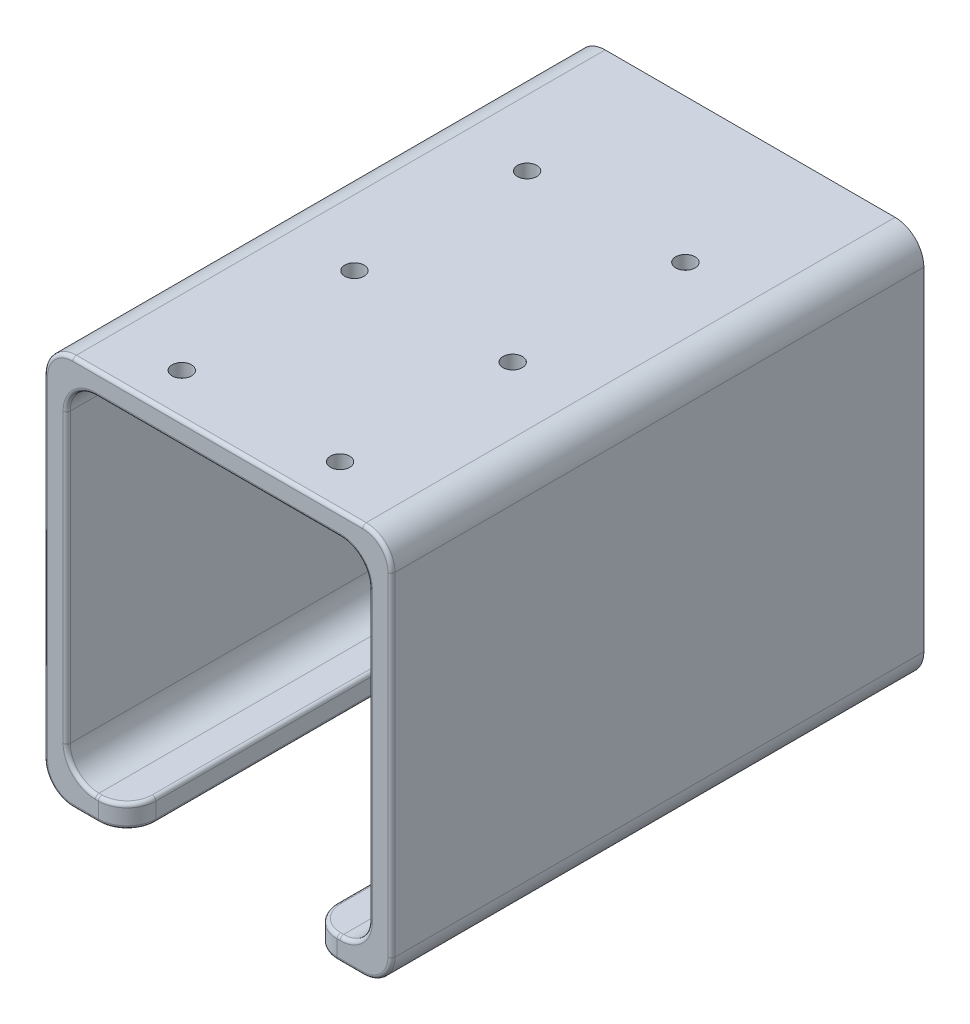
from build123d import *

# Parameters (mm, degrees)
SKETCH2_W               = 76.675
SKETCH2_H               = 86.2
SKETCH2_W_2             = 66.675
SKETCH2_H_2             = 76.2
BOSS_EXTRUDE1_DEPTH     = 152.4
CUT_EXTRUDE1_REACH      = 181.237
FILLET1_R               = 6.35
SKETCH5_R               = 2.13995
CUT_EXTRUDE2_DEPTH      = 177.886867535
LPATTERN1_COUNT         = 4
LPATTERN1_PITCH         = 38.1
MIRROR3_COPY_1_SKETCH_R = 2.13995
MIRROR3_COPY_1_DEPTH    = 177.886867535
MIRROR3_COPY_2_SKETCH_R = 2.13995
MIRROR3_COPY_2_DEPTH    = 177.886867535
MIRROR3_COPY_3_SKETCH_R = 2.13995
MIRROR3_COPY_3_DEPTH    = 177.886867535
CUT_EXTRUDE3_START      = -34.925
CUT_EXTRUDE3_DEPTH      = 34.925
FILLET2_R               = 0.79375


with BuildPart() as part:
    # Sketch2 → Boss-Extrude1 (new body)
    with BuildSketch(Plane.XY):
        Rectangle(SKETCH2_W, SKETCH2_H)
        Rectangle(SKETCH2_W_2, SKETCH2_H_2, mode=Mode.SUBTRACT)
    extrude(amount=BOSS_EXTRUDE1_DEPTH)

    # Sketch3 → Cut-Extrude1 (cut, up to next)
    with BuildSketch(Plane.XZ.offset(43.1), mode=Mode.PRIVATE) as cut_extrude1_sk1:
        with BuildLine():
            Line((20, 152.4), (20, 70.8))
            ThreePointArc((20, 70.8), (0, 50.8), (-20, 70.8))
            Line((-20, 70.8), (-20, 152.4))
            ThreePointArc((-20, 152.4), (0, 172.4), (20, 152.4))
        make_face()
    cut_extrude1_tool1 = extrude(cut_extrude1_sk1.sketch, amount=-CUT_EXTRUDE1_REACH, mode=Mode.PRIVATE) & part.part
    add(cut_extrude1_tool1.solids().sort_by_distance((0, -43.1, 111.6))[0], mode=Mode.SUBTRACT)

    # Fillet1
    fillet1_edges = [part.edges().sort_by_distance(p)[0] for p in [
        (-38.3375, 43.1, 76.2),
        (-38.3375, -43.1, 76.2),
        (38.3375, -43.1, 76.2),
        (38.3375, 43.1, 76.2),
        (33.3375, 38.1, 76.2),
        (-33.3375, 38.1, 76.2),
        (-33.3375, -38.1, 76.2),
        (33.3375, -38.1, 76.2),
        (20, -40.6, 152.4),
        (-20, -40.6, 152.4),
    ]]
    fillet(fillet1_edges, radius=FILLET1_R)

    # Sketch5 → Cut-Extrude2 (cut, through all)
    with BuildSketch(Plane.XZ.offset(-38.1)):
        with Locations((-17.4625, 142.875)):
            Circle(SKETCH5_R)
    cut_extrude2 = extrude(amount=-CUT_EXTRUDE2_DEPTH, mode=Mode.SUBTRACT)

    # Sketch6 → Cut-Revolve1 (revolve, cut)
    with BuildSketch(Plane(origin=(-17.4625, 0, 0), x_dir=(0, -1, 0), z_dir=(-1, 0, 0))):
        Polygon((-38.1, 138.7475), (-38.1, 142.875), (-42.2275, 142.875), align=None)
    cut_revolve1 = revolve(axis=Axis((-17.4625, 38.1, 142.875), (0, 1, 0)), mode=Mode.SUBTRACT)

    # LPattern1: Cut-Extrude2, Cut-Revolve1 ×4
    with Locations(*[(0, 0, -i * LPATTERN1_PITCH) for i in range(1, LPATTERN1_COUNT)]):
        add(cut_extrude2, mode=Mode.SUBTRACT)
        add(cut_revolve1, mode=Mode.SUBTRACT)

    # Mirror3: Cut-Extrude2, Cut-Revolve1 across plane
    add(cut_extrude2.mirror(Plane(origin=(0, 0, 0), x_dir=(0, 0, 1), z_dir=(1, 0, 0))), mode=Mode.SUBTRACT)
    add(cut_revolve1.mirror(Plane(origin=(0, 0, 0), x_dir=(0, 0, 1), z_dir=(1, 0, 0))), mode=Mode.SUBTRACT)

    # Mirror3 copy 1 sketch → Mirror3 copy 1 (cut, through all)
    with BuildSketch(Plane(origin=(0, 38.1, -38.1), x_dir=(-1, 0, 0), z_dir=(0, -1, 0))):
        with Locations((-17.4625, -142.875)):
            Circle(MIRROR3_COPY_1_SKETCH_R)
    extrude(amount=-MIRROR3_COPY_1_DEPTH, mode=Mode.SUBTRACT)

    # Mirror3 copy 2 sketch → Mirror3 copy 2 (cut, through all)
    with BuildSketch(Plane(origin=(0, 38.1, -76.2), x_dir=(-1, 0, 0), z_dir=(0, -1, 0))):
        with Locations((-17.4625, -142.875)):
            Circle(MIRROR3_COPY_2_SKETCH_R)
    extrude(amount=-MIRROR3_COPY_2_DEPTH, mode=Mode.SUBTRACT)

    # Mirror3 copy 3 sketch → Mirror3 copy 3 (cut, through all)
    with BuildSketch(Plane(origin=(0, 38.1, -114.3), x_dir=(-1, 0, 0), z_dir=(0, -1, 0))):
        with Locations((-17.4625, -142.875)):
            Circle(MIRROR3_COPY_3_SKETCH_R)
    extrude(amount=-MIRROR3_COPY_3_DEPTH, mode=Mode.SUBTRACT)

    # Mirror3 copy 4 sketch → Mirror3 copy 4 (revolve, cut)
    with BuildSketch(Plane(origin=(17.4625, 0, -38.1), x_dir=(0, -1, 0), z_dir=(1, 0, 0))):
        Polygon((-38.1, -138.7475), (-38.1, -142.875), (-42.2275, -142.875), align=None)
    revolve(axis=Axis((17.4625, 38.1, 104.775), (0, -1, 0)), mode=Mode.SUBTRACT)

    # Mirror3 copy 5 sketch → Mirror3 copy 5 (revolve, cut)
    with BuildSketch(Plane(origin=(17.4625, 0, -76.2), x_dir=(0, -1, 0), z_dir=(1, 0, 0))):
        Polygon((-38.1, -138.7475), (-38.1, -142.875), (-42.2275, -142.875), align=None)
    revolve(axis=Axis((17.4625, 38.1, 66.675), (0, -1, 0)), mode=Mode.SUBTRACT)

    # Mirror3 copy 6 sketch → Mirror3 copy 6 (revolve, cut)
    with BuildSketch(Plane(origin=(17.4625, 0, -114.3), x_dir=(0, -1, 0), z_dir=(1, 0, 0))):
        Polygon((-38.1, -138.7475), (-38.1, -142.875), (-42.2275, -142.875), align=None)
    revolve(axis=Axis((17.4625, 38.1, 28.575), (0, -1, 0)), mode=Mode.SUBTRACT)

    # Sketch7 → Cut-Extrude3 (cut)
    with BuildSketch(Plane(origin=(0, 0, 0), x_dir=(-1, 0, 0), z_dir=(0, 0, -1)).offset(CUT_EXTRUDE3_START)):
        with BuildLine():
            Line((38.3375, -36.75), (38.3375, 36.75))
            ThreePointArc((38.3375, 36.75), (36.477628061, 41.240128061), (31.9875, 43.1))
            Line((31.9875, 43.1), (-31.9875, 43.1))
            ThreePointArc((-31.9875, 43.1), (-36.477628061, 41.240128061), (-38.3375, 36.75))
            Line((-38.3375, 36.75), (-38.3375, -36.75))
            ThreePointArc((-38.3375, -36.75), (-36.477628061, -41.240128061), (-31.9875, -43.1))
            Line((-31.9875, -43.1), (31.9875, -43.1))
            ThreePointArc((31.9875, -43.1), (36.477628061, -41.240128061), (38.3375, -36.75))
        make_face()
    extrude(amount=CUT_EXTRUDE3_DEPTH, mode=Mode.SUBTRACT)

    # Fillet2
    fillet2_edges = [part.edges().sort_by_distance(p)[0] for p in [
        (-21.859871939, -43.1, 150.540128061),
        (-29.16875, -43.1, 152.4),
        (-36.477628061, -41.240128061, 152.4),
        (-38.3375, 0, 152.4),
        (-36.477628061, 41.240128061, 152.4),
        (0, 43.1, 152.4),
        (36.477628061, 41.240128061, 152.4),
        (38.3375, 0, 152.4),
        (36.477628061, -41.240128061, 152.4),
        (29.16875, -43.1, 152.4),
        (21.859871939, -43.1, 150.540128061),
        (20, -43.1, 108.425),
        (0, -43.1, 50.8),
        (-20, -38.1, 108.425),
        (-21.859871939, -38.1, 150.540128061),
        (-26.66875, -38.1, 152.4),
        (-31.477628061, -36.240128061, 152.4),
        (-33.3375, 0, 152.4),
        (-31.477628061, 36.240128061, 152.4),
        (0, 38.1, 152.4),
        (31.477628061, 36.240128061, 152.4),
        (33.3375, 0, 152.4),
        (31.477628061, -36.240128061, 152.4),
        (26.66875, -38.1, 152.4),
        (21.859871939, -38.1, 150.540128061),
        (20, -38.1, 108.425),
        (-20, -43.1, 108.425),
        (0, -38.1, 50.8),
    ]]
    fillet(fillet2_edges, radius=FILLET2_R)


solid = part.part
